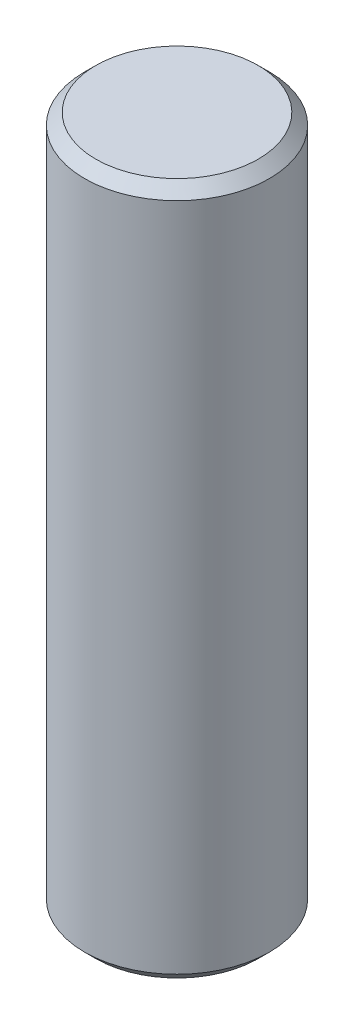
from build123d import *

# Parameters (mm, degrees)
SKETCH1_R           = 4.125
BOSS_EXTRUDE1_DEPTH = 30.9
CHAMFER1_SIZE       = 0.5


with BuildPart() as part:
    # Sketch1 → Boss-Extrude1 (new body)
    with BuildSketch(Plane(origin=(0, 0, 0), x_dir=(1, 0, 0), z_dir=(0, 1, 0))):
        Circle(SKETCH1_R)
    extrude(amount=BOSS_EXTRUDE1_DEPTH)

    # Chamfer1
    chamfer1_edges = [part.edges().sort_by_distance(p)[0] for p in [
        (-4.125, 0, 0),
        (-4.125, 30.9, 0),
    ]]
    chamfer(chamfer1_edges, length=CHAMFER1_SIZE)


solid = part.part
